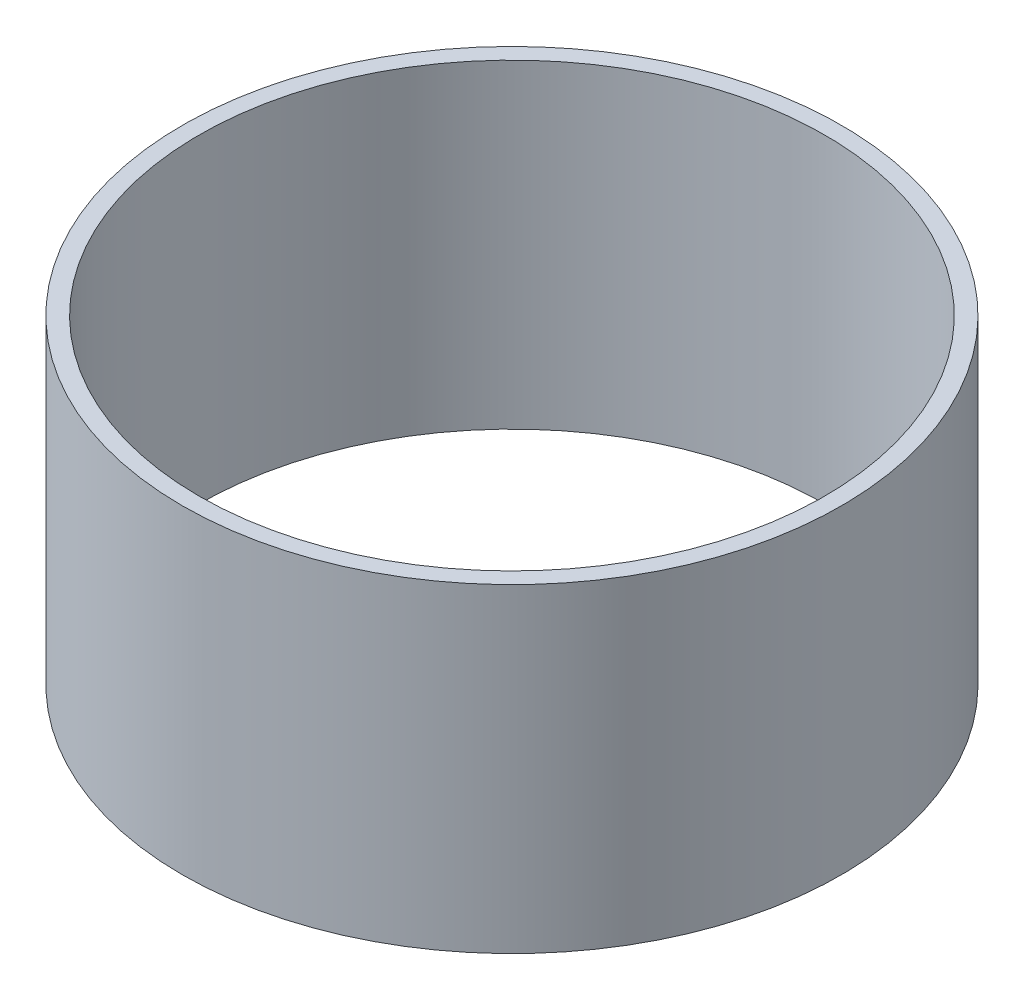
from build123d import *

# Parameters (mm, degrees)
SKETCH1_R           = 93.6625
SKETCH1_R_2         = 88.9
BOSS_EXTRUDE1_DEPTH = 45.40758


with BuildPart() as part:
    # Sketch1 → Boss-Extrude1 (new body, symmetric)
    with BuildSketch(Plane(origin=(0, 0, 0), x_dir=(1, 0, 0), z_dir=(0, 1, 0))):
        Circle(SKETCH1_R)
        Circle(SKETCH1_R_2, mode=Mode.SUBTRACT)
    extrude(amount=BOSS_EXTRUDE1_DEPTH, both=True)


solid = part.part
